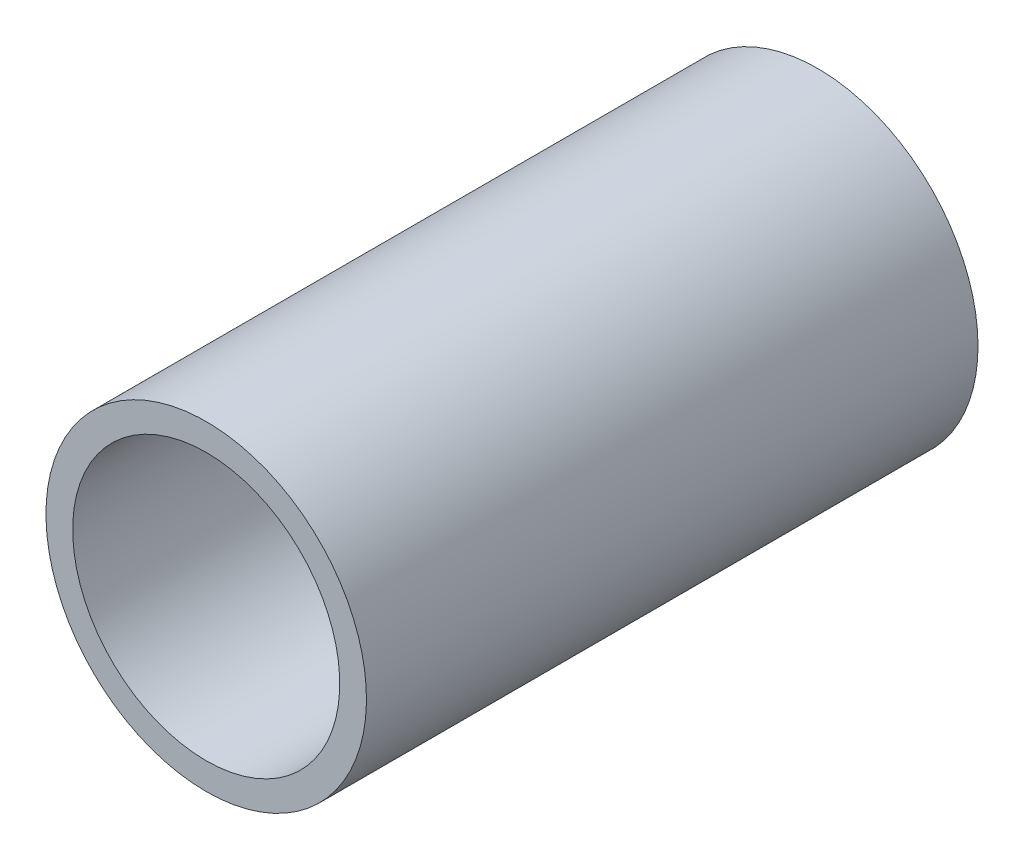
from build123d import *

# Parameters (mm, degrees)
SKETCH1_R           = 6
SKETCH1_R_2         = 5
BOSS_EXTRUDE1_DEPTH = 22.89703


with BuildPart() as part:
    # Sketch1 → Boss-Extrude1 (new body)
    with BuildSketch(Plane.XY):
        Circle(SKETCH1_R)
        Circle(SKETCH1_R_2, mode=Mode.SUBTRACT)
    extrude(amount=BOSS_EXTRUDE1_DEPTH)


solid = part.part
